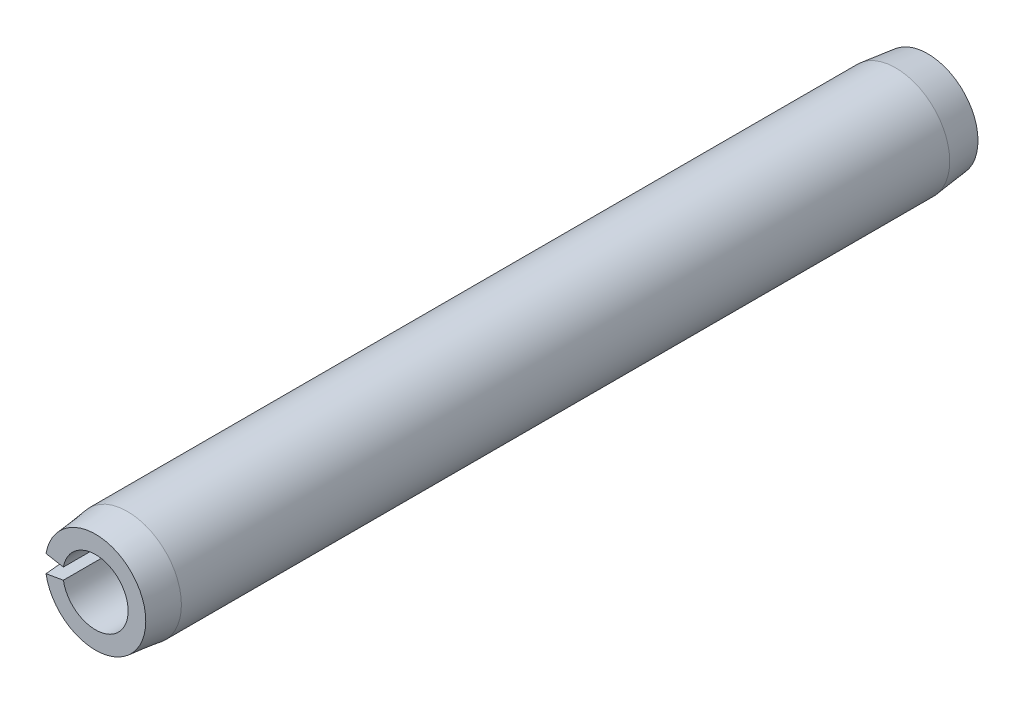
from build123d import *

# Parameters (mm, degrees)
EXTRUDE1_DEPTH = 15.875


with BuildPart() as part:
    # Sketch1 → Extrude1 (new body, symmetric)
    with BuildSketch(Plane.XY):
        with BuildLine():
            Line((-2.026143471, 0.357263761), (-1.225691729, 0.216122522))
            ThreePointArc((-1.225691729, 0.216122522), (1.2446, 0), (-1.225691729, -0.216122522))
            Line((-1.225691729, -0.216122522), (-2.026143471, -0.357263761))
            ThreePointArc((-2.026143471, -0.357263761), (2.0574, 0), (-2.026143471, 0.357263761))
        make_face()
    extrude(amount=EXTRUDE1_DEPTH, both=True)

    # Sketch2 → Cut-Revolve1 (revolve, cut)
    with BuildSketch(Plane(origin=(0, 0, 0), x_dir=(0, 0, -1), z_dir=(1, 0, 0))):
        Polygon((15.875, 2.0574), (15.875, 1.9177), (14.6558, 2.0574), align=None)
        Polygon((-14.6558, 2.0574), (-15.875, 2.0574), (-15.875, 1.9177), align=None)
    revolve(axis=Axis((0, 0, -15.875), (0, 0, 1)), mode=Mode.SUBTRACT)


solid = part.part
